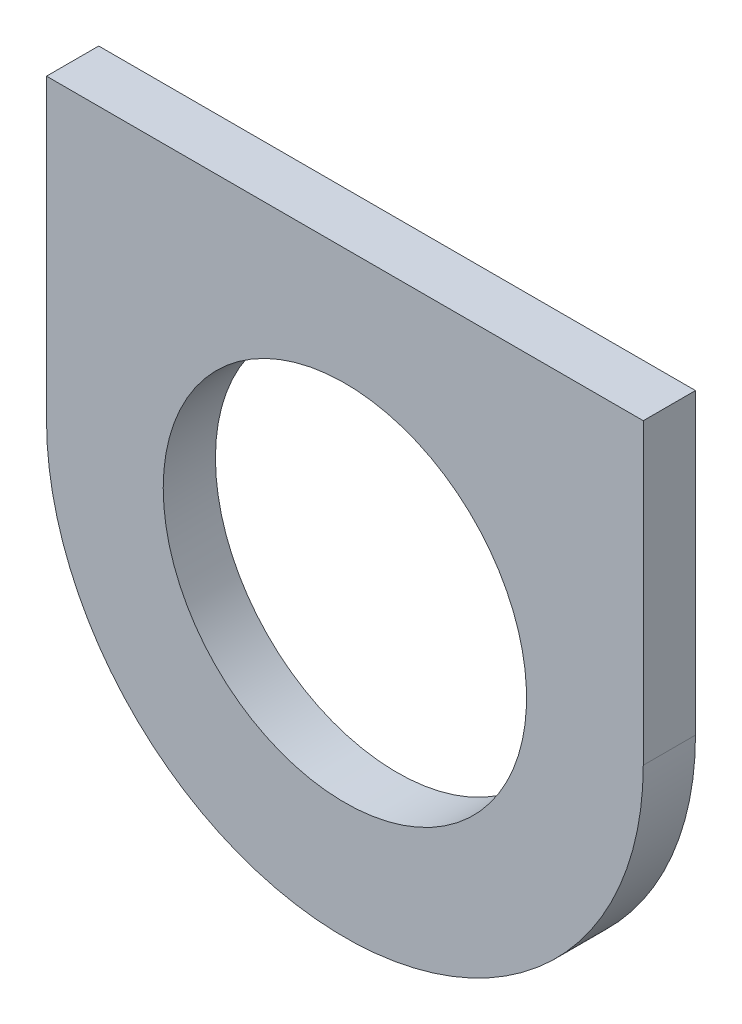
from build123d import *

# Parameters (mm, degrees)
SKETCH1_R           = 1.7399
BOSS_EXTRUDE1_DEPTH = 0.5


with BuildPart() as part:
    # Sketch1 → Boss-Extrude1 (new body)
    with BuildSketch(Plane(origin=(0, 0, 764.167404568), x_dir=(-1, 0, 0), z_dir=(0, 0, -1))):
        with BuildLine():
            Line((108.204437713, 637.468625119), (108.204437713, 640.326125119))
            Line((108.204437713, 640.326125119), (111.061937713, 640.326125119))
            Line((111.061937713, 640.326125119), (113.919437713, 640.326125119))
            Line((113.919437713, 640.326125119), (113.919437713, 637.468625119))
            ThreePointArc((113.919437713, 637.468625119), (111.061937713, 634.611125119), (108.204437713, 637.468625119))
        make_face()
        with Locations((111.061937713, 637.468625119)):
            Circle(SKETCH1_R, mode=Mode.SUBTRACT)
    extrude(amount=BOSS_EXTRUDE1_DEPTH)


solid = part.part
